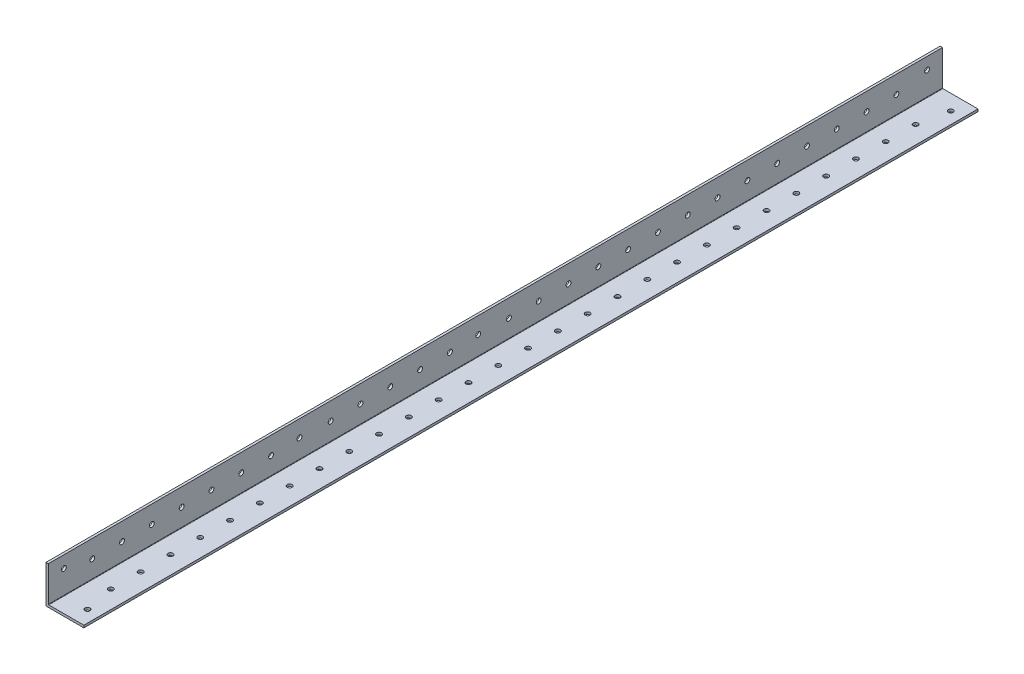
from build123d import *

# Parameters (mm, degrees)
BOSS_EXTRUDE1_DEPTH = 1219.2
FILLET1_R           = 0.254
SKETCH4_W           = 1838.4
SKETCH4_H           = 74.945320812
CUT_EXTRUDE1_DEPTH  = 60
SKETCH5_R           = 1.65
CUT_EXTRUDE2_DEPTH  = 10
SKETCH9_R           = 1.65
CUT_EXTRUDE6_DEPTH  = 60


with BuildPart() as part:
    # Sketch3 → Boss-Extrude1 (new, symmetric)
    with BuildSketch(Plane.XY):
        Polygon((1.5875, 25.4), (0, 25.4), (0, 0), (25.4, 0), (25.4, 1.5875), (1.5875, 1.5875), align=None)
    extrude(amount=BOSS_EXTRUDE1_DEPTH, both=True)

    # Fillet1
    fillet1_edges = [part.edges().sort_by_distance(p)[0] for p in [
        (1.5875, 1.5875, 0),
    ]]
    fillet(fillet1_edges, radius=FILLET1_R)

    # Sketch4 → Cut-Extrude1 (cut)
    with BuildSketch(Plane.ZY):
        with Locations((-300, 37.472660406)):
            Rectangle(SKETCH4_W, SKETCH4_H)
    extrude(amount=-CUT_EXTRUDE1_DEPTH, mode=Mode.SUBTRACT)

    # Sketch5 → Cut-Extrude2 (cut)
    with BuildSketch(Plane(origin=(0, 1.5875, 0), x_dir=(1, 0, 0), z_dir=(0, 1, 0))):
        with Locations(Location((17.4625, -629.5759, 0), (0, 0, 180))):
            Circle(SKETCH5_R)
        with Locations(Location((17.4625, -1208.8241, 0), (0, 0, 180))):
            Circle(SKETCH5_R)
        with Locations(Location((13.49375, -1189.2, 0), (0, 0, 180))):
            Circle(SKETCH5_R)
        with Locations(Location((13.49375, -1169.2, 0), (0, 0, 180))):
            Circle(SKETCH5_R)
        with Locations(Location((13.49375, -1149.2, 0), (0, 0, 180))):
            Circle(SKETCH5_R)
        with Locations(Location((13.49375, -1129.2, 0), (0, 0, 180))):
            Circle(SKETCH5_R)
        with Locations(Location((13.49375, -1109.2, 0), (0, 0, 180))):
            Circle(SKETCH5_R)
        with Locations(Location((13.49375, -1089.2, 0), (0, 0, 180))):
            Circle(SKETCH5_R)
        with Locations(Location((13.49375, -1069.2, 0), (0, 0, 180))):
            Circle(SKETCH5_R)
        with Locations(Location((13.49375, -1049.2, 0), (0, 0, 180))):
            Circle(SKETCH5_R)
        with Locations(Location((13.49375, -1029.2, 0), (0, 0, 180))):
            Circle(SKETCH5_R)
        with Locations(Location((13.49375, -1009.2, 0), (0, 0, 180))):
            Circle(SKETCH5_R)
        with Locations(Location((13.49375, -989.2, 0), (0, 0, 180))):
            Circle(SKETCH5_R)
        with Locations(Location((13.49375, -969.2, 0), (0, 0, 180))):
            Circle(SKETCH5_R)
        with Locations(Location((13.49375, -949.2, 0), (0, 0, 180))):
            Circle(SKETCH5_R)
        with Locations(Location((13.49375, -929.2, 0), (0, 0, 180))):
            Circle(SKETCH5_R)
        with Locations(Location((13.49375, -909.2, 0), (0, 0, 180))):
            Circle(SKETCH5_R)
        with Locations(Location((13.49375, -889.2, 0), (0, 0, 180))):
            Circle(SKETCH5_R)
        with Locations(Location((13.49375, -869.2, 0), (0, 0, 180))):
            Circle(SKETCH5_R)
        with Locations(Location((13.49375, -849.2, 0), (0, 0, 180))):
            Circle(SKETCH5_R)
        with Locations(Location((13.49375, -829.2, 0), (0, 0, 180))):
            Circle(SKETCH5_R)
        with Locations(Location((13.49375, -809.2, 0), (0, 0, 180))):
            Circle(SKETCH5_R)
        with Locations(Location((13.49375, -789.2, 0), (0, 0, 180))):
            Circle(SKETCH5_R)
        with Locations(Location((13.49375, -769.2, 0), (0, 0, 180))):
            Circle(SKETCH5_R)
        with Locations(Location((13.49375, -749.2, 0), (0, 0, 180))):
            Circle(SKETCH5_R)
        with Locations(Location((13.49375, -729.2, 0), (0, 0, 180))):
            Circle(SKETCH5_R)
        with Locations(Location((13.49375, -709.2, 0), (0, 0, 180))):
            Circle(SKETCH5_R)
        with Locations(Location((13.49375, -689.2, 0), (0, 0, 180))):
            Circle(SKETCH5_R)
        with Locations(Location((13.49375, -669.2, 0), (0, 0, 180))):
            Circle(SKETCH5_R)
        with Locations(Location((13.49375, -649.2, 0), (0, 0, 180))):
            Circle(SKETCH5_R)
    extrude(amount=-CUT_EXTRUDE2_DEPTH, mode=Mode.SUBTRACT)

    # Sketch9 → Cut-Extrude6 (cut)
    with BuildSketch(Plane(origin=(1.5875, 0, 0), x_dir=(0, 0, -1), z_dir=(1, 0, 0))):
        with Locations((-629.5759, 17.4625)):
            Circle(SKETCH9_R)
        with Locations((-1208.8241, 17.4625)):
            Circle(SKETCH9_R)
        with Locations((-1050.70625, 14.2875)):
            Circle(SKETCH9_R)
        with Locations((-930.70625, 14.2875)):
            Circle(SKETCH9_R)
        with Locations((-1189.765175, 13.49375)):
            Circle(SKETCH9_R)
        with Locations((-1169.765175, 13.49375)):
            Circle(SKETCH9_R)
        with Locations((-1149.765175, 13.49375)):
            Circle(SKETCH9_R)
        with Locations((-1129.765175, 13.49375)):
            Circle(SKETCH9_R)
        with Locations((-1109.765175, 13.49375)):
            Circle(SKETCH9_R)
        with Locations((-1089.765175, 13.49375)):
            Circle(SKETCH9_R)
        with Locations((-1069.765175, 13.49375)):
            Circle(SKETCH9_R)
        with Locations((-1029.765175, 13.49375)):
            Circle(SKETCH9_R)
        with Locations((-1009.765175, 13.49375)):
            Circle(SKETCH9_R)
        with Locations((-989.765175, 13.49375)):
            Circle(SKETCH9_R)
        with Locations((-969.765175, 13.49375)):
            Circle(SKETCH9_R)
        with Locations((-949.765175, 13.49375)):
            Circle(SKETCH9_R)
        with Locations((-650.141075, 13.49375)):
            Circle(SKETCH9_R)
        with Locations((-670.141075, 13.49375)):
            Circle(SKETCH9_R)
        with Locations((-690.141075, 13.49375)):
            Circle(SKETCH9_R)
        with Locations((-710.141075, 13.49375)):
            Circle(SKETCH9_R)
        with Locations((-730.141075, 13.49375)):
            Circle(SKETCH9_R)
        with Locations((-750.141075, 13.49375)):
            Circle(SKETCH9_R)
        with Locations((-770.141075, 13.49375)):
            Circle(SKETCH9_R)
        with Locations((-790.141075, 13.49375)):
            Circle(SKETCH9_R)
        with Locations((-810.141075, 13.49375)):
            Circle(SKETCH9_R)
        with Locations((-830.141075, 13.49375)):
            Circle(SKETCH9_R)
        with Locations((-850.141075, 13.49375)):
            Circle(SKETCH9_R)
        with Locations((-870.141075, 13.49375)):
            Circle(SKETCH9_R)
        with Locations((-890.141075, 13.49375)):
            Circle(SKETCH9_R)
        with Locations((-910.141075, 13.49375)):
            Circle(SKETCH9_R)
    extrude(amount=-CUT_EXTRUDE6_DEPTH, mode=Mode.SUBTRACT)


solid = part.part
